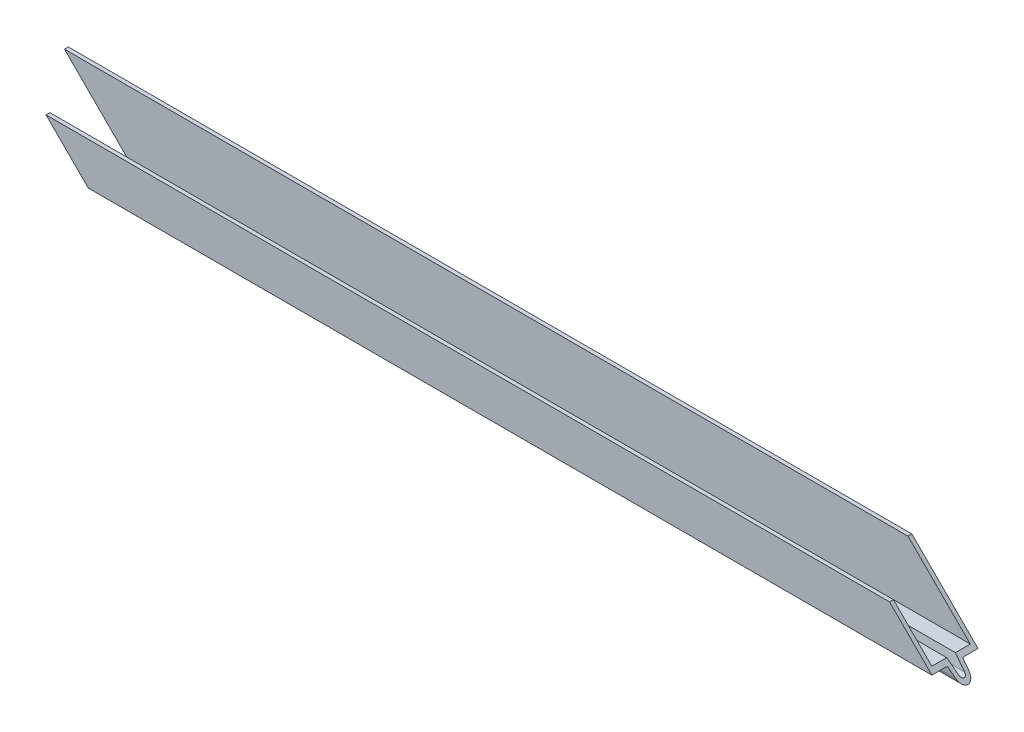
from build123d import *

# Parameters (mm, degrees)
BOSS_EXTRUDE1_DEPTH         = 152.4
CUT_FRONT_LEFT_BOTTOM_DEPTH = 16.24
CUT_FRONT_RIGHT_TOP_DEPTH   = 16.24


with BuildPart() as part:
    # Sketch1 → Boss-Extrude1 (new body, symmetric)
    with BuildSketch(Plane(origin=(0, 0, 0), x_dir=(0, 0, -1), z_dir=(1, 0, 0))):
        with BuildLine():
            Line((7.62, 0), (7.62, -21.844))
            Line((7.62, -21.844), (2.54, -21.844))
            Line((2.54, -21.844), (2.202186415, -24.247668555))
            ThreePointArc((2.202186415, -24.247668555), (0, -26.162), (-2.202186415, -24.247668555))
            Line((-2.202186415, -24.247668555), (-2.54, -21.844))
            Line((-2.54, -21.844), (-7.62, -21.844))
            Line((-7.62, -21.844), (-7.62, -7.874))
            Line((-7.62, -7.874), (-6.35, -7.874))
            Line((-6.35, -7.874), (-6.35, -20.574))
            Line((-6.35, -20.574), (-1.436005843, -20.574))
            Line((-1.436005843, -20.574), (-0.944545968, -24.070918717))
            ThreePointArc((-0.944545968, -24.070918717), (0, -24.892), (0.944545968, -24.070918717))
            Line((0.944545968, -24.070918717), (1.436005843, -20.574))
            Line((1.436005843, -20.574), (6.35, -20.574))
            Line((6.35, -20.574), (6.35, 0))
            Line((6.35, 0), (7.62, 0))
        make_face()
    extrude(amount=BOSS_EXTRUDE1_DEPTH, both=True)

    # Sketch12 → Cut-Front-Left-Bottom (cut, through all)
    with BuildSketch(Plane.XY.offset(7.62)):
        Polygon((-152.4, 0), (-126.238, -26.162), (-152.4, -26.162), align=None)
    extrude(amount=-CUT_FRONT_LEFT_BOTTOM_DEPTH, mode=Mode.SUBTRACT)

    # Sketch7 → Cut-Front-Right-Top (cut, through all)
    with BuildSketch(Plane.XY.offset(7.62)):
        Polygon((152.4, -26.162), (126.238, 0), (152.4, 0), align=None)
    extrude(amount=-CUT_FRONT_RIGHT_TOP_DEPTH, mode=Mode.SUBTRACT)


solid = part.part
